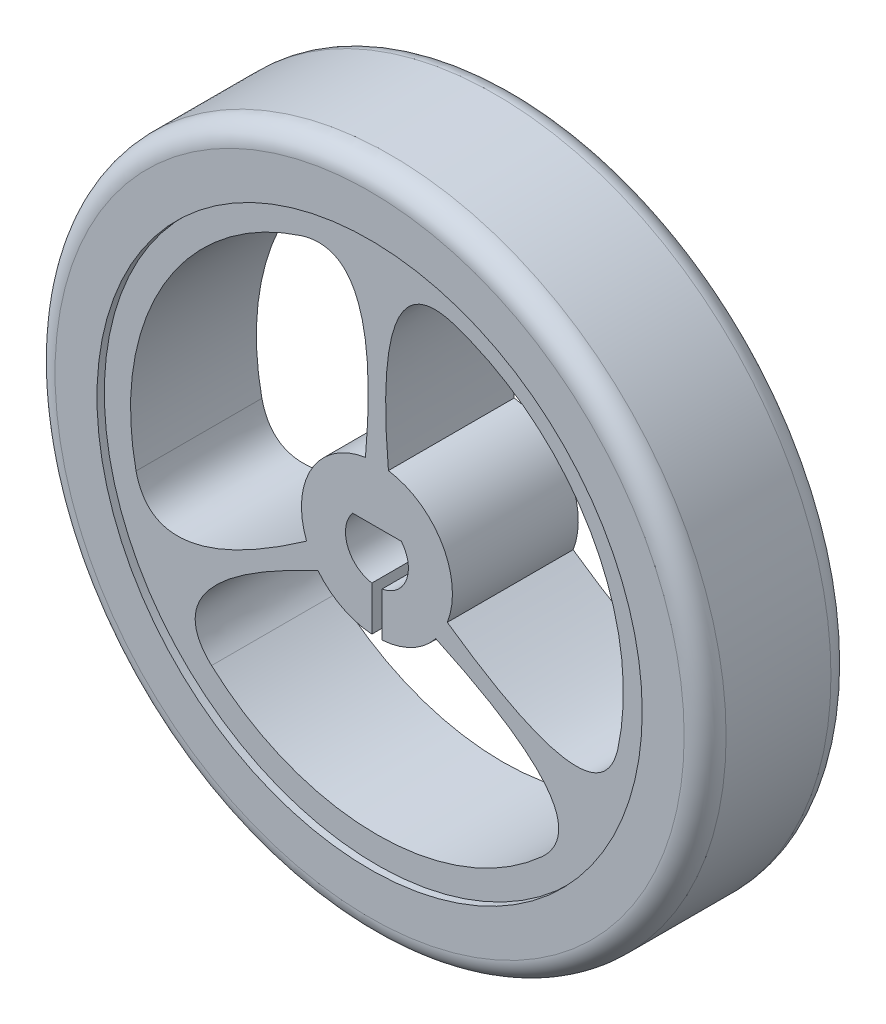
from build123d import *

# Parameters (mm, degrees)
IZIM1_R                          = 14.3
Y_KSEKLIK_EKSTR_ZYON2_DEPTH      = 3
IZIM2_R                          = 13
Y_KSEKLIK_EKSTR_ZYON3_DEPTH      = 1.5
IZIM3_R                          = 13
Y_KSEKLIK_EKSTR_ZYON4_DEPTH      = 1.5
KES_EKSTR_ZYON1_DEPTH            = 7
KES_EKSTR_ZYON3_DEPTH            = 7
IZIM6_R                          = 16
IZIM6_R_2                        = 13
Y_KSEKLIK_EKSTR_ZYON5_DEPTH      = 0.35
Y_KSEKLIK_EKSTR_ZYON5_DEPTH_BACK = 6.65
RADYUS1_R                        = 1
RADYUS2_R                        = 1


with BuildPart() as part:
    # Çizim1 → Yükseklik-Ekstrüzyon2 (new body)
    with BuildSketch(Plane.XY):
        Circle(IZIM1_R)
    extrude(amount=Y_KSEKLIK_EKSTR_ZYON2_DEPTH)

    # Çizim2 → Yükseklik-Ekstrüzyon3 (add)
    with BuildSketch(Plane.XY.offset(3)):
        Circle(IZIM2_R)
    extrude(amount=Y_KSEKLIK_EKSTR_ZYON3_DEPTH)

    # Çizim3 → Yükseklik-Ekstrüzyon4 (add)
    with BuildSketch(Plane(origin=(0, 0, 0), x_dir=(-1, 0, 0), z_dir=(0, 0, -1))):
        Circle(IZIM3_R)
    extrude(amount=Y_KSEKLIK_EKSTR_ZYON4_DEPTH)

    # Çizim4 → Kes-Ekstrüzyon1 (cut)
    with BuildSketch(Plane.XY.offset(4.5)):
        with BuildLine():
            add(Edge.make_bspline(
                [(-0.547346557, 3.558147235), (0.233958313, 12.343828963), (-3.6, 11.184922888)],
                knots=[0, 0, 0, 0.973142828, 0.973142828, 0.973142828], degree=2))
            ThreePointArc((-3.6, 11.184922888), (-3.707741279, 11.149670605), (-3.81513744, 11.113380508))
            ThreePointArc((-3.81513744, 11.113380508), (-10.175798494, 5.875), (-11.532038562, -2.252684312))
            ThreePointArc((-11.532038562, -2.252684312), (-11.509768628, -2.363837165), (-11.48642736, -2.47476999))
            add(Edge.make_bspline(
                [(-3.355119175, -1.305057594), (-10.573090305, -6.374528324), (-11.48642736, -2.47476999)],
                knots=[0, 0, 0, 0.973142828, 0.973142828, 0.973142828], degree=2))
            ThreePointArc((-3.355119175, -1.305057594), (-3.117691454, 1.8), (-0.547346557, 3.558147235))
        make_face()
        with BuildLine():
            add(Edge.make_bspline(
                [(3.355119175, -1.305057594), (10.573090305, -6.374528324), (11.48642736, -2.47476999)],
                knots=[0, 0, 0, 0.973142828, 0.973142828, 0.973142828], degree=2))
            ThreePointArc((11.48642736, -2.47476999), (11.509768628, -2.363837165), (11.532038562, -2.252684312))
            ThreePointArc((11.532038562, -2.252684312), (10.175798494, 5.875), (3.81513744, 11.113380508))
            ThreePointArc((3.81513744, 11.113380508), (3.707741279, 11.149670605), (3.6, 11.184922888))
            add(Edge.make_bspline(
                [(0.547346557, 3.558147235), (-0.233958313, 12.343828963), (3.6, 11.184922888)],
                knots=[0, 0, 0, 0.973142828, 0.973142828, 0.973142828], degree=2))
            ThreePointArc((0.547346557, 3.558147235), (3.117691454, 1.8), (3.355119175, -1.305057594))
        make_face()
        with BuildLine():
            add(Edge.make_bspline(
                [(-2.807772617, -2.253089641), (-10.807048618, -5.969300639), (-7.88642736, -8.710152897)],
                knots=[0, 0, 0, 0.973142828, 0.973142828, 0.973142828], degree=2))
            ThreePointArc((-7.88642736, -8.710152897), (-7.802027349, -8.785833441), (-7.716901122, -8.860696196))
            ThreePointArc((-7.716901122, -8.860696196), (0, -11.75), (7.716901122, -8.860696196))
            ThreePointArc((7.716901122, -8.860696196), (7.802027349, -8.785833441), (7.88642736, -8.710152897))
            add(Edge.make_bspline(
                [(2.807772617, -2.253089641), (10.807048618, -5.969300639), (7.88642736, -8.710152897)],
                knots=[0, 0, 0, 0.973142828, 0.973142828, 0.973142828], degree=2))
            ThreePointArc((2.807772617, -2.253089641), (0, -3.6), (-2.807772617, -2.253089641))
        make_face()
    extrude(amount=-KES_EKSTR_ZYON1_DEPTH, mode=Mode.SUBTRACT)

    # Çizim5 → Kes-Ekstrüzyon3 (cut)
    with BuildSketch(Plane.XY.offset(4.5)):
        with BuildLine():
            Line((-0.243283358, -3.591770205), (-0.243283358, -3.70476627))
            Line((-0.243283358, -3.70476627), (0.246794301, -3.70476627))
            Line((0.246794301, -3.70476627), (0.246794301, -3.591770205))
            Line((0.246794301, -3.591770205), (0.246794301, -1.479558236))
            ThreePointArc((0.246794301, -1.479558236), (1.403567335, -0.529149068), (1.162136883, 0.948386981))
            Line((1.162136883, 0.948386981), (-1.162136883, 0.948386981))
            ThreePointArc((-1.162136883, 0.948386981), (-1.402938645, -0.530813677), (-0.243283358, -1.480139591))
            Line((-0.243283358, -1.480139591), (-0.243283358, -3.591770205))
        make_face()
    extrude(amount=-KES_EKSTR_ZYON3_DEPTH, mode=Mode.SUBTRACT)

    # Çizim6 → Yükseklik-Ekstrüzyon5 (add, two sides)
    with BuildSketch(Plane.XY.offset(4.5)) as y_kseklik_ekstr_zyon5_sk:
        Circle(IZIM6_R)
        Circle(IZIM6_R_2, mode=Mode.SUBTRACT)
    extrude(amount=Y_KSEKLIK_EKSTR_ZYON5_DEPTH)
    extrude(y_kseklik_ekstr_zyon5_sk.sketch, amount=-Y_KSEKLIK_EKSTR_ZYON5_DEPTH_BACK)

    # Radyus1
    radyus1_edges = [part.edges().sort_by_distance(p)[0] for p in [
        (-16, 0, 4.85),
    ]]
    fillet(radyus1_edges, radius=RADYUS1_R)

    # Radyus2
    radyus2_edges = [part.edges().sort_by_distance(p)[0] for p in [
        (-16, 0, -2.15),
    ]]
    fillet(radyus2_edges, radius=RADYUS2_R)


solid = part.part
